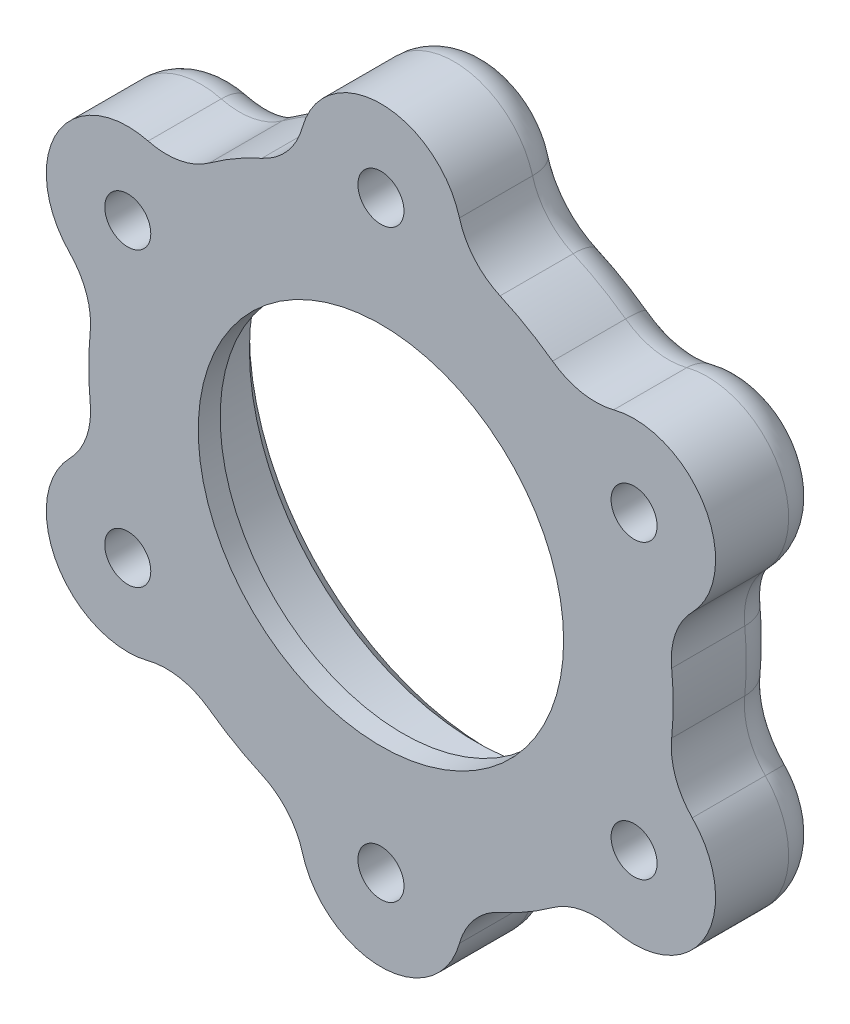
from build123d import *

# Parameters (mm, degrees)
SKETCH1_R           = 31
BOSS_EXTRUDE1_DEPTH = 15
SKETCH2_R           = 31
SKETCH2_R_2         = 25
BOSS_EXTRUDE2_DEPTH = 3
FILLET1_R           = 10
SKETCH3_R           = 3.15
CUT_EXTRUDE1_DEPTH  = 6
FILLET2_R           = 5
CHAMFER1_SIZE       = 2


with BuildPart() as part:
    # Sketch1 → Boss-Extrude1 (new body)
    with BuildSketch(Plane.XY):
        with BuildLine():
            ThreePointArc((-11.041172351, 38.44596875), (0, 51.15), (11.041172351, 38.44596875))
            ThreePointArc((11.041172351, 38.44596875), (20, 34.641016151), (27.774599435, 28.784920118))
            ThreePointArc((27.774599435, 28.784920118), (44.297199404, 25.575), (38.815771786, 9.661048632))
            ThreePointArc((38.815771786, 9.661048632), (40, 0), (38.815771786, -9.661048632))
            ThreePointArc((38.815771786, -9.661048632), (44.297199404, -25.575), (27.774599435, -28.784920118))
            ThreePointArc((27.774599435, -28.784920118), (20, -34.641016151), (11.041172351, -38.44596875))
            ThreePointArc((11.041172351, -38.44596875), (0, -51.15), (-11.041172351, -38.44596875))
            ThreePointArc((-11.041172351, -38.44596875), (-20, -34.641016151), (-27.774599435, -28.784920118))
            ThreePointArc((-27.774599435, -28.784920118), (-44.297199404, -25.575), (-38.815771786, -9.661048632))
            ThreePointArc((-38.815771786, -9.661048632), (-40, 0), (-38.815771786, 9.661048632))
            ThreePointArc((-38.815771786, 9.661048632), (-44.297199404, 25.575), (-27.774599435, 28.784920118))
            ThreePointArc((-27.774599435, 28.784920118), (-20, 34.641016151), (-11.041172351, 38.44596875))
        make_face()
        Circle(SKETCH1_R, mode=Mode.SUBTRACT)
    extrude(amount=BOSS_EXTRUDE1_DEPTH)

    # Sketch2 → Boss-Extrude2 (add)
    with BuildSketch(Plane.XY.offset(15)):
        Circle(SKETCH2_R)
        Circle(SKETCH2_R_2, mode=Mode.SUBTRACT)
    extrude(amount=-BOSS_EXTRUDE2_DEPTH)

    # Fillet1
    fillet1_edges = [part.edges().sort_by_distance(p)[0] for p in [
        (-11.041172351, 38.44596875, 7.5),
        (11.041172351, 38.44596875, 7.5),
        (27.774599435, 28.784920118, 7.5),
        (38.815771786, 9.661048632, 7.5),
        (38.815771786, -9.661048632, 7.5),
        (27.774599435, -28.784920118, 7.5),
        (11.041172351, -38.44596875, 7.5),
        (-11.041172351, -38.44596875, 7.5),
        (-27.774599435, -28.784920118, 7.5),
        (-38.815771786, -9.661048632, 7.5),
        (-38.815771786, 9.661048632, 7.5),
        (-27.774599435, 28.784920118, 7.5),
    ]]
    fillet(fillet1_edges, radius=FILLET1_R)

    # Sketch3 → Cut-Extrude1 (cut)
    with BuildSketch(Plane.XY.offset(15)):
        with Locations((0, 40)):
            Circle(SKETCH3_R)
        with Locations((34.641016151, 20)):
            Circle(SKETCH3_R)
        with Locations((34.641016151, -20)):
            Circle(SKETCH3_R)
        with Locations((0, -40)):
            Circle(SKETCH3_R)
        with Locations((-34.641016151, -20)):
            Circle(SKETCH3_R)
        with Locations((-34.641016151, 20)):
            Circle(SKETCH3_R)
    extrude(amount=-CUT_EXTRUDE1_DEPTH, mode=Mode.SUBTRACT)

    # Fillet2
    fillet2_edges = [part.edges().sort_by_distance(p)[0] for p in [
        (-20, 34.641016151, 0),
        (0, 51.15, 0),
        (20, 34.641016151, 0),
        (44.297199404, 25.575, 0),
        (40, 0, 0),
        (44.297199404, -25.575, 0),
        (20, -34.641016151, 0),
        (0, -51.15, 0),
        (-20, -34.641016151, 0),
        (-44.297199404, -25.575, 0),
        (-40, 0, 0),
        (-44.297199404, 25.575, 0),
        (-12.80137158, 39.133185001, 0),
        (12.80137158, 39.133185001, 0),
        (27.489646552, 30.652905493, 0),
        (40.291018132, 8.480279509, 0),
        (40.291018132, -8.480279509, 0),
        (27.489646552, -30.652905493, 0),
        (12.80137158, -39.133185001, 0),
        (-12.80137158, -39.133185001, 0),
        (-27.489646552, -30.652905493, 0),
        (-40.291018132, -8.480279509, 0),
        (-40.291018132, 8.480279509, 0),
        (-27.489646552, 30.652905493, 0),
    ]]
    fillet(fillet2_edges, radius=FILLET2_R)

    # Chamfer1
    chamfer1_edges = [part.edges().sort_by_distance(p)[0] for p in [
        (-31, 0, 0),
    ]]
    chamfer(chamfer1_edges, length=CHAMFER1_SIZE)


solid = part.part
